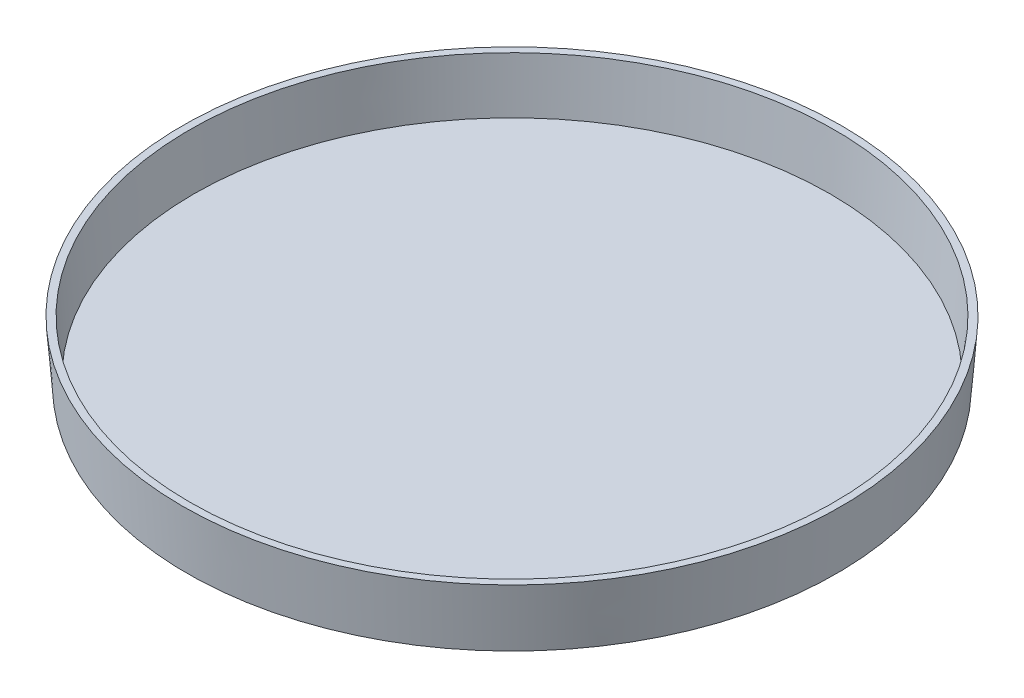
from build123d import *

# Parameters (mm, degrees)
SHELL1_T = -1.016


with BuildPart() as part:
    # Sketch2 → Revolve1 (revolve)
    with BuildSketch(Plane.XY, mode=Mode.PRIVATE) as revolve1_sk:
        Polygon((0, 0), (46.4185, 0), (47.0916, 8.6614), (0, 8.6614), align=None)
    revolve(revolve1_sk.sketch.rotate(Axis((0, 0, 0), (0, 1, 0)), 90), axis=Axis((0, 0, 0), (0, 1, 0)))

    # Shell1
    shell1_openings = [part.faces().sort_by_distance(p)[0] for p in [
        (0, 8.6614, 0),
    ]]
    offset(amount=SHELL1_T, openings=shell1_openings, kind=Kind.INTERSECTION)


solid = part.part
